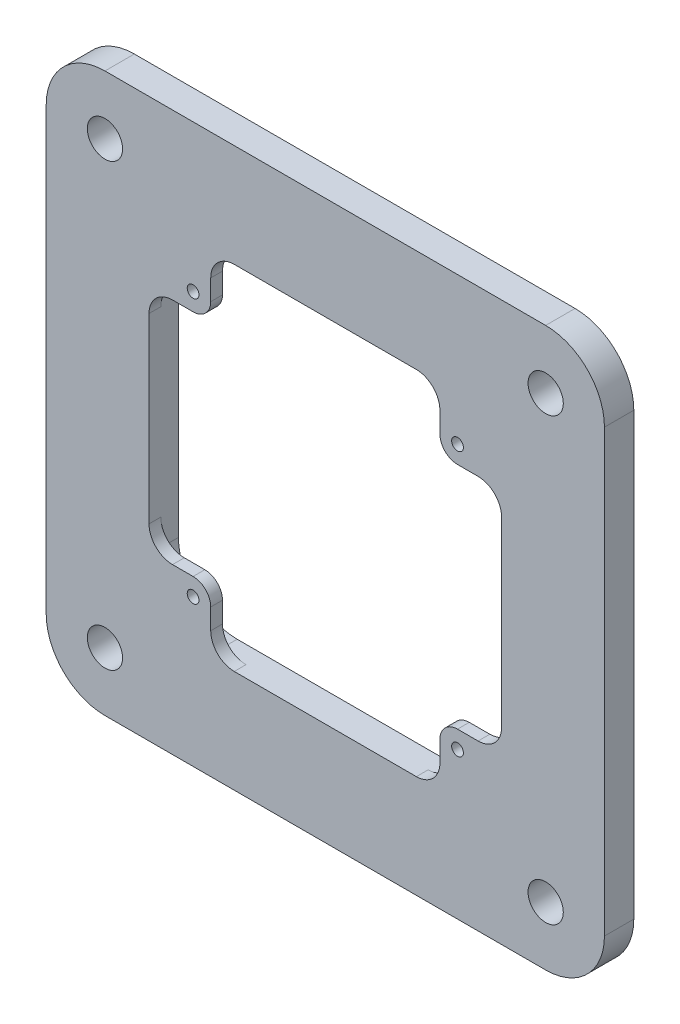
from build123d import *

# Parameters (mm, degrees)
SKETCH_1_R          = 1
SKETCH_1_R_2        = 3
EXTRUDE_1_DEPTH     = 5
CUT_EXTRUDE_1_DEPTH = 3


with BuildPart() as part:
    # 草图1 → 凸台-拉伸1 (new body)
    with BuildSketch(Plane.XY):
        with BuildLine():
            Line((-37.5, 47.5), (37.5, 47.5))
            ThreePointArc((37.5, 47.5), (44.571067812, 44.571067812), (47.5, 37.5))
            Line((47.5, 37.5), (47.5, -37.5))
            ThreePointArc((47.5, -37.5), (44.571067812, -44.571067812), (37.5, -47.5))
            Line((37.5, -47.5), (-37.5, -47.5))
            ThreePointArc((-37.5, -47.5), (-44.571067812, -44.571067812), (-47.5, -37.5))
            Line((-47.5, -37.5), (-47.5, 37.5))
            ThreePointArc((-47.5, 37.5), (-44.571067812, 44.571067812), (-37.5, 47.5))
        make_face()
        with Locations((-22.5, 22.5)):
            Circle(SKETCH_1_R, mode=Mode.SUBTRACT)
        with Locations((22.5, 22.5)):
            Circle(SKETCH_1_R, mode=Mode.SUBTRACT)
        with Locations((22.5, -22.5)):
            Circle(SKETCH_1_R, mode=Mode.SUBTRACT)
        with Locations((-22.5, -22.5)):
            Circle(SKETCH_1_R, mode=Mode.SUBTRACT)
        with Locations((37.5, 37.5)):
            Circle(SKETCH_1_R_2, mode=Mode.SUBTRACT)
        with Locations((-37.5, 37.5)):
            Circle(SKETCH_1_R_2, mode=Mode.SUBTRACT)
        with Locations((-37.5, -37.5)):
            Circle(SKETCH_1_R_2, mode=Mode.SUBTRACT)
        with Locations((37.5, -37.5)):
            Circle(SKETCH_1_R_2, mode=Mode.SUBTRACT)
        with BuildLine():
            Line((15.5, 30), (-15.5, 30))
            ThreePointArc((-15.5, 30), (-18.328427125, 28.828427125), (-19.5, 26))
            Line((-19.5, 26), (-19.5, 22.5))
            ThreePointArc((-19.5, 22.5), (-20.378679656, 20.378679656), (-22.5, 19.5))
            Line((-22.5, 19.5), (-26, 19.5))
            ThreePointArc((-26, 19.5), (-28.828427125, 18.328427125), (-30, 15.5))
            Line((-30, 15.5), (-30, -15.5))
            ThreePointArc((-30, -15.5), (-28.828427125, -18.328427125), (-26, -19.5))
            Line((-26, -19.5), (-22.5, -19.5))
            ThreePointArc((-22.5, -19.5), (-20.378679656, -20.378679656), (-19.5, -22.5))
            Line((-19.5, -22.5), (-19.5, -26))
            ThreePointArc((-19.5, -26), (-18.328427125, -28.828427125), (-15.5, -30))
            Line((-15.5, -30), (15.5, -30))
            ThreePointArc((15.5, -30), (18.328427125, -28.828427125), (19.5, -26))
            Line((19.5, -26), (19.5, -22.5))
            ThreePointArc((19.5, -22.5), (20.378679656, -20.378679656), (22.5, -19.5))
            Line((22.5, -19.5), (26, -19.5))
            ThreePointArc((26, -19.5), (28.828427125, -18.328427125), (30, -15.5))
            Line((30, -15.5), (30, 15.5))
            ThreePointArc((30, 15.5), (28.828427125, 18.328427125), (26, 19.5))
            Line((26, 19.5), (22.5, 19.5))
            ThreePointArc((22.5, 19.5), (20.378679656, 20.378679656), (19.5, 22.5))
            Line((19.5, 22.5), (19.5, 26))
            ThreePointArc((19.5, 26), (18.328427125, 28.828427125), (15.5, 30))
        make_face(mode=Mode.SUBTRACT)
    extrude(amount=EXTRUDE_1_DEPTH)

    # 草图2 → 切除-拉伸1 (cut)
    with BuildSketch(Plane(origin=(0, 0, 0), x_dir=(-1, 0, 0), z_dir=(0, 0, -1))):
        with BuildLine():
            Line((20, -30), (-20, -30))
            ThreePointArc((-20, -30), (-27.071067812, -27.071067812), (-30, -20))
            Line((-30, -20), (-30, 20))
            ThreePointArc((-30, 20), (-27.071067812, 27.071067812), (-20, 30))
            Line((-20, 30), (20, 30))
            ThreePointArc((20, 30), (27.071067812, 27.071067812), (30, 20))
            Line((30, 20), (30, -20))
            ThreePointArc((30, -20), (27.071067812, -27.071067812), (20, -30))
        make_face()
    extrude(amount=-CUT_EXTRUDE_1_DEPTH, mode=Mode.SUBTRACT)


solid = part.part
